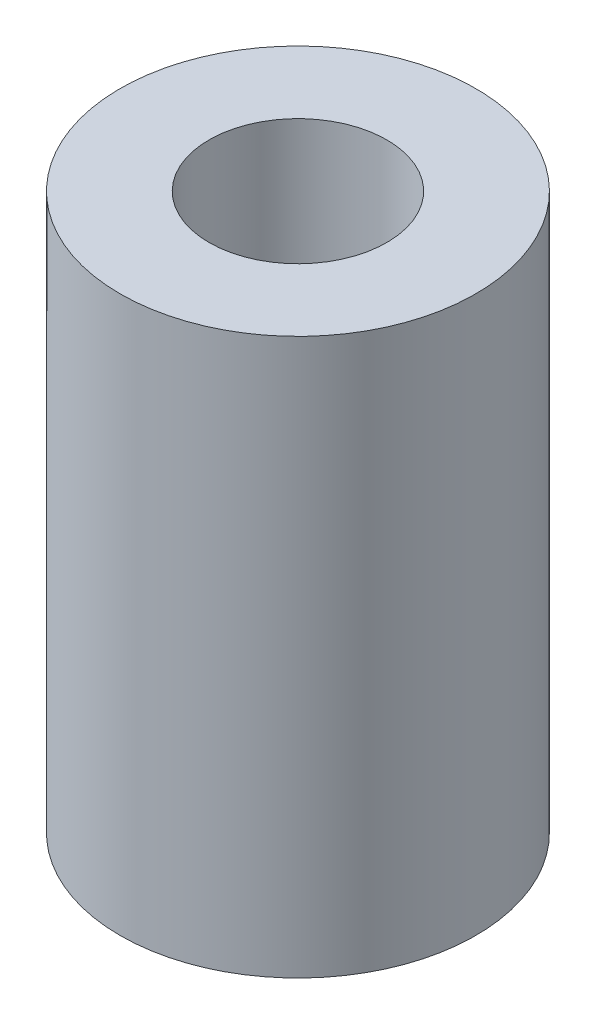
from build123d import *

# Parameters (mm, degrees)
SKETCH1_R           = 4
SKETCH1_R_2         = 2
BOSS_EXTRUDE1_DEPTH = 12.5


with BuildPart() as part:
    # Sketch1 → Boss-Extrude1 (new body)
    with BuildSketch(Plane(origin=(0, 0, 0), x_dir=(1, 0, 0), z_dir=(0, 1, 0))):
        Circle(SKETCH1_R)
        Circle(SKETCH1_R_2, mode=Mode.SUBTRACT)
    extrude(amount=BOSS_EXTRUDE1_DEPTH)


solid = part.part
